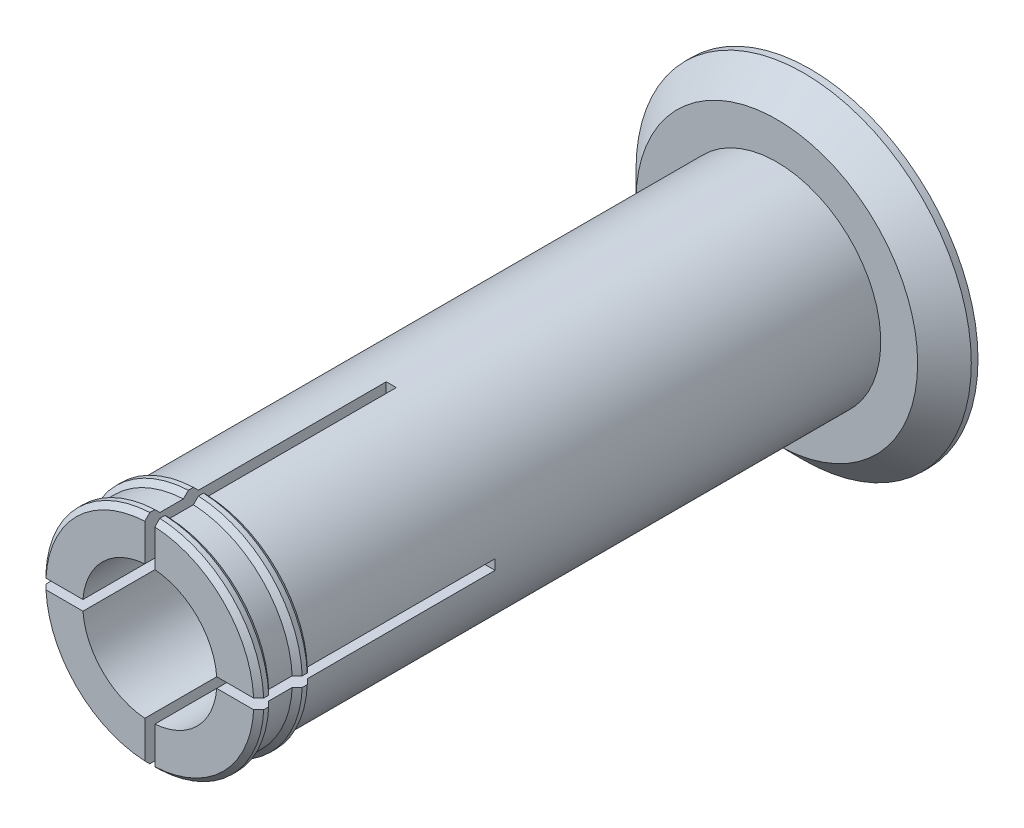
from build123d import *

# Parameters (mm, degrees)
AXLE_BASE_SKETCH_R     = 15.5
AXLE_DEPTH             = 93.5
GUARD_BASE_R           = 25
GUARD_DEPTH            = 5
INNER_AXLE_HOLE_BASE_R = 10
INNER_AXLE_HOLE_DEPTH  = 99.5
BEND_ROOM_BASE_W       = 1.5
BEND_ROOM_BASE_H       = 50
BEND_ROOM_1_DEPTH      = 36
BEND_ROOM_2_COUNT      = 2
BEND_ROOM_2_ANGLE      = 90
CHAMFER1_SIZE          = 4


with BuildPart() as part:
    # Axle base sketch → Axle (new body)
    with BuildSketch(Plane.XY):
        Circle(AXLE_BASE_SKETCH_R)
    extrude(amount=AXLE_DEPTH)

    # Guard base → Guard (add)
    with BuildSketch(Plane(origin=(0, 0, 0), x_dir=(-1, 0, 0), z_dir=(0, 0, -1))):
        Circle(GUARD_BASE_R)
    extrude(amount=GUARD_DEPTH)

    # Inner axle hole base → Inner axle hole (cut, through all)
    with BuildSketch(Plane.XY.offset(93.5)):
        Circle(INNER_AXLE_HOLE_BASE_R)
    extrude(amount=-INNER_AXLE_HOLE_DEPTH, mode=Mode.SUBTRACT)

    # Mate ring base → Mate rings (revolve)
    with BuildSketch(Plane(origin=(0, 0, 0), x_dir=(1, 0, 0), z_dir=(0, 1, 0))):
        Polygon((15.5, -93.5), (16.25, -92.75), (16.25, -92), (15.5, -91.25), align=None)
        Polygon((15.5, -87.75), (16.25, -87), (16.25, -86.25), (15.5, -85.5), align=None)
    revolve(axis=Axis((0, 0, 0), (0, 0, -1)))

    # Bend room base → Bend room 1 (cut)
    with BuildSketch(Plane.XY.offset(93.5)):
        Rectangle(BEND_ROOM_BASE_W, BEND_ROOM_BASE_H)
    bend_room_1 = extrude(amount=-BEND_ROOM_1_DEPTH, mode=Mode.SUBTRACT)

    # Bend room 2: Bend room 1 ×2 about axis
    bend_room_2_axis = Axis((0, 0, 0), (0, 0, -1))
    for i in range(1, BEND_ROOM_2_COUNT):
        add(bend_room_1.rotate(bend_room_2_axis, i * BEND_ROOM_2_ANGLE / (BEND_ROOM_2_COUNT - 1)), mode=Mode.SUBTRACT)

    # Chamfer1
    chamfer1_edges = [part.edges().sort_by_distance(p)[0] for p in [
        (25, 0, 0),
    ]]
    chamfer(chamfer1_edges, length=CHAMFER1_SIZE)


solid = part.part
